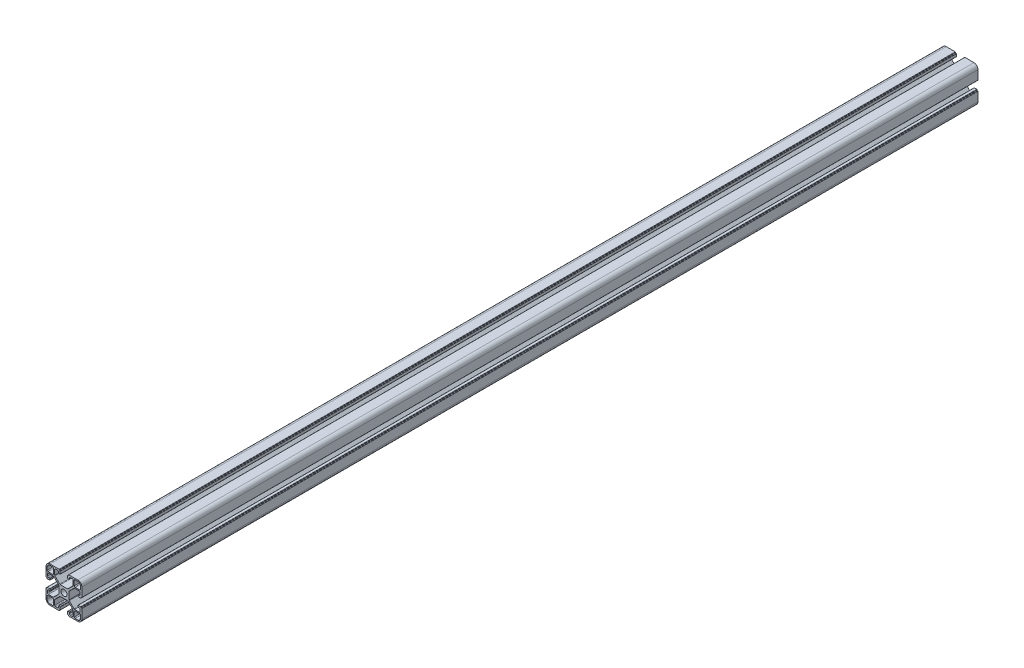
from build123d import *

# Parameters (mm, degrees)
SKETCH_1_R      = 3.4
EXTRUDE_1_DEPTH = 1000


with BuildPart() as part:
    # Эскиз1 → Бобышка-Вытянуть1 (new body)
    with BuildSketch(Plane.XY):
        with BuildLine():
            Line((-20, 10.25), (-20, 15.5))
            ThreePointArc((-20, 15.5), (-18.681980515, 18.681980515), (-15.5, 20))
            Line((-15.5, 20), (-10.25, 20))
            Line((-10.25, 20), (-5.4, 20))
            ThreePointArc((-5.4, 20), (-5.187867966, 19.912132034), (-5.1, 19.7))
            Line((-5.1, 19.7), (-5.1, 19.3))
            ThreePointArc((-5.1, 19.3), (-5.012132034, 19.087867966), (-4.8, 19))
            Line((-4.8, 19), (-4.4, 19))
            ThreePointArc((-4.4, 19), (-4.187867966, 18.912132034), (-4.1, 18.7))
            Line((-4.1, 18.7), (-4.1, 16))
            ThreePointArc((-4.1, 16), (-4.187867966, 15.787867966), (-4.4, 15.7))
            Line((-4.4, 15.7), (-5.8, 15.7))
            ThreePointArc((-5.8, 15.7), (-6.012132034, 15.787867966), (-6.1, 16))
            Line((-6.1, 16), (-6.1, 17.2))
            ThreePointArc((-6.1, 17.2), (-6.392893219, 17.907106781), (-7.1, 18.2))
            Line((-7.1, 18.2), (-9.25, 18.2))
            ThreePointArc((-9.25, 18.2), (-9.957106781, 17.907106781), (-10.25, 17.2))
            Line((-10.25, 17.2), (-10.25, 11.964213562))
            ThreePointArc((-10.25, 11.964213562), (-10.173879533, 11.58153013), (-9.957106781, 11.257106781))
            Line((-9.957106781, 11.257106781), (-4.692893219, 5.992893219))
            ThreePointArc((-4.692893219, 5.992893219), (-4.36846987, 5.776120467), (-3.985786438, 5.7))
            Line((-3.985786438, 5.7), (3.985786438, 5.7))
            ThreePointArc((3.985786438, 5.7), (4.36846987, 5.776120467), (4.692893219, 5.992893219))
            Line((4.692893219, 5.992893219), (9.957106781, 11.257106781))
            ThreePointArc((9.957106781, 11.257106781), (10.173879533, 11.58153013), (10.25, 11.964213562))
            Line((10.25, 11.964213562), (10.25, 17.2))
            ThreePointArc((10.25, 17.2), (9.957106781, 17.907106781), (9.25, 18.2))
            Line((9.25, 18.2), (7.1, 18.2))
            ThreePointArc((7.1, 18.2), (6.392893219, 17.907106781), (6.1, 17.2))
            Line((6.1, 17.2), (6.1, 16))
            ThreePointArc((6.1, 16), (6.012132034, 15.787867966), (5.8, 15.7))
            Line((5.8, 15.7), (4.4, 15.7))
            ThreePointArc((4.4, 15.7), (4.187867966, 15.787867966), (4.1, 16))
            Line((4.1, 16), (4.1, 18.7))
            ThreePointArc((4.1, 18.7), (4.187867966, 18.912132034), (4.4, 19))
            Line((4.4, 19), (4.8, 19))
            ThreePointArc((4.8, 19), (5.012132034, 19.087867966), (5.1, 19.3))
            Line((5.1, 19.3), (5.1, 19.7))
            ThreePointArc((5.1, 19.7), (5.187867966, 19.912132034), (5.4, 20))
            Line((5.4, 20), (10.25, 20))
            Line((10.25, 20), (15.5, 20))
            ThreePointArc((15.5, 20), (18.681980515, 18.681980515), (20, 15.5))
            Line((20, 15.5), (20, 10.25))
            Line((20, 10.25), (20, 5.4))
            ThreePointArc((20, 5.4), (19.912132034, 5.187867966), (19.7, 5.1))
            Line((19.7, 5.1), (19.3, 5.1))
            ThreePointArc((19.3, 5.1), (19.087867966, 5.012132034), (19, 4.8))
            Line((19, 4.8), (19, 4.4))
            ThreePointArc((19, 4.4), (18.912132034, 4.187867966), (18.7, 4.1))
            Line((18.7, 4.1), (16, 4.1))
            ThreePointArc((16, 4.1), (15.787867966, 4.187867966), (15.7, 4.4))
            Line((15.7, 4.4), (15.7, 5.8))
            ThreePointArc((15.7, 5.8), (15.787867966, 6.012132034), (16, 6.1))
            Line((16, 6.1), (17.2, 6.1))
            ThreePointArc((17.2, 6.1), (17.907106781, 6.392893219), (18.2, 7.1))
            Line((18.2, 7.1), (18.2, 9.25))
            ThreePointArc((18.2, 9.25), (17.907106781, 9.957106781), (17.2, 10.25))
            Line((17.2, 10.25), (11.964213562, 10.25))
            ThreePointArc((11.964213562, 10.25), (11.58153013, 10.173879533), (11.257106781, 9.957106781))
            Line((11.257106781, 9.957106781), (5.992893219, 4.692893219))
            ThreePointArc((5.992893219, 4.692893219), (5.776120467, 4.36846987), (5.7, 3.985786438))
            Line((5.7, 3.985786438), (5.7, -3.985786438))
            ThreePointArc((5.7, -3.985786438), (5.776120467, -4.36846987), (5.992893219, -4.692893219))
            Line((5.992893219, -4.692893219), (11.257106781, -9.957106781))
            ThreePointArc((11.257106781, -9.957106781), (11.58153013, -10.173879533), (11.964213562, -10.25))
            Line((11.964213562, -10.25), (17.2, -10.25))
            ThreePointArc((17.2, -10.25), (17.907106781, -9.957106781), (18.2, -9.25))
            Line((18.2, -9.25), (18.2, -7.1))
            ThreePointArc((18.2, -7.1), (17.907106781, -6.392893219), (17.2, -6.1))
            Line((17.2, -6.1), (16, -6.1))
            ThreePointArc((16, -6.1), (15.787867966, -6.012132034), (15.7, -5.8))
            Line((15.7, -5.8), (15.7, -4.4))
            ThreePointArc((15.7, -4.4), (15.787867966, -4.187867966), (16, -4.1))
            Line((16, -4.1), (18.7, -4.1))
            ThreePointArc((18.7, -4.1), (18.912132034, -4.187867966), (19, -4.4))
            Line((19, -4.4), (19, -4.8))
            ThreePointArc((19, -4.8), (19.087867966, -5.012132034), (19.3, -5.1))
            Line((19.3, -5.1), (19.7, -5.1))
            ThreePointArc((19.7, -5.1), (19.912132034, -5.187867966), (20, -5.4))
            Line((20, -5.4), (20, -10.25))
            Line((20, -10.25), (20, -15.5))
            ThreePointArc((20, -15.5), (18.681980515, -18.681980515), (15.5, -20))
            Line((15.5, -20), (10.25, -20))
            Line((10.25, -20), (5.4, -20))
            ThreePointArc((5.4, -20), (5.187867966, -19.912132034), (5.1, -19.7))
            Line((5.1, -19.7), (5.1, -19.3))
            ThreePointArc((5.1, -19.3), (5.012132034, -19.087867966), (4.8, -19))
            Line((4.8, -19), (4.4, -19))
            ThreePointArc((4.4, -19), (4.187867966, -18.912132034), (4.1, -18.7))
            Line((4.1, -18.7), (4.1, -16))
            ThreePointArc((4.1, -16), (4.187867966, -15.787867966), (4.4, -15.7))
            Line((4.4, -15.7), (5.8, -15.7))
            ThreePointArc((5.8, -15.7), (6.012132034, -15.787867966), (6.1, -16))
            Line((6.1, -16), (6.1, -17.2))
            ThreePointArc((6.1, -17.2), (6.392893219, -17.907106781), (7.1, -18.2))
            Line((7.1, -18.2), (9.25, -18.2))
            ThreePointArc((9.25, -18.2), (9.957106781, -17.907106781), (10.25, -17.2))
            Line((10.25, -17.2), (10.25, -11.964213562))
            ThreePointArc((10.25, -11.964213562), (10.173879533, -11.58153013), (9.957106781, -11.257106781))
            Line((9.957106781, -11.257106781), (4.692893219, -5.992893219))
            ThreePointArc((4.692893219, -5.992893219), (4.36846987, -5.776120467), (3.985786438, -5.7))
            Line((3.985786438, -5.7), (-3.985786438, -5.7))
            ThreePointArc((-3.985786438, -5.7), (-4.36846987, -5.776120467), (-4.692893219, -5.992893219))
            Line((-4.692893219, -5.992893219), (-9.957106781, -11.257106781))
            ThreePointArc((-9.957106781, -11.257106781), (-10.173879533, -11.58153013), (-10.25, -11.964213562))
            Line((-10.25, -11.964213562), (-10.25, -17.2))
            ThreePointArc((-10.25, -17.2), (-9.957106781, -17.907106781), (-9.25, -18.2))
            Line((-9.25, -18.2), (-7.1, -18.2))
            ThreePointArc((-7.1, -18.2), (-6.392893219, -17.907106781), (-6.1, -17.2))
            Line((-6.1, -17.2), (-6.1, -16))
            ThreePointArc((-6.1, -16), (-6.012132034, -15.787867966), (-5.8, -15.7))
            Line((-5.8, -15.7), (-4.4, -15.7))
            ThreePointArc((-4.4, -15.7), (-4.187867966, -15.787867966), (-4.1, -16))
            Line((-4.1, -16), (-4.1, -18.7))
            ThreePointArc((-4.1, -18.7), (-4.187867966, -18.912132034), (-4.4, -19))
            Line((-4.4, -19), (-4.8, -19))
            ThreePointArc((-4.8, -19), (-5.012132034, -19.087867966), (-5.1, -19.3))
            Line((-5.1, -19.3), (-5.1, -19.7))
            ThreePointArc((-5.1, -19.7), (-5.187867966, -19.912132034), (-5.4, -20))
            Line((-5.4, -20), (-10.25, -20))
            Line((-10.25, -20), (-15.5, -20))
            ThreePointArc((-15.5, -20), (-18.681980515, -18.681980515), (-20, -15.5))
            Line((-20, -15.5), (-20, -10.25))
            Line((-20, -10.25), (-20, -5.4))
            ThreePointArc((-20, -5.4), (-19.912132034, -5.187867966), (-19.7, -5.1))
            Line((-19.7, -5.1), (-19.3, -5.1))
            ThreePointArc((-19.3, -5.1), (-19.087867966, -5.012132034), (-19, -4.8))
            Line((-19, -4.8), (-19, -4.4))
            ThreePointArc((-19, -4.4), (-18.912132034, -4.187867966), (-18.7, -4.1))
            Line((-18.7, -4.1), (-16, -4.1))
            ThreePointArc((-16, -4.1), (-15.787867966, -4.187867966), (-15.7, -4.4))
            Line((-15.7, -4.4), (-15.7, -5.8))
            ThreePointArc((-15.7, -5.8), (-15.787867966, -6.012132034), (-16, -6.1))
            Line((-16, -6.1), (-17.2, -6.1))
            ThreePointArc((-17.2, -6.1), (-17.907106781, -6.392893219), (-18.2, -7.1))
            Line((-18.2, -7.1), (-18.2, -9.25))
            ThreePointArc((-18.2, -9.25), (-17.907106781, -9.957106781), (-17.2, -10.25))
            Line((-17.2, -10.25), (-11.964213562, -10.25))
            ThreePointArc((-11.964213562, -10.25), (-11.58153013, -10.173879533), (-11.257106781, -9.957106781))
            Line((-11.257106781, -9.957106781), (-5.992893219, -4.692893219))
            ThreePointArc((-5.992893219, -4.692893219), (-5.776120467, -4.36846987), (-5.7, -3.985786438))
            Line((-5.7, -3.985786438), (-5.7, 3.985786438))
            ThreePointArc((-5.7, 3.985786438), (-5.776120467, 4.36846987), (-5.992893219, 4.692893219))
            Line((-5.992893219, 4.692893219), (-11.257106781, 9.957106781))
            ThreePointArc((-11.257106781, 9.957106781), (-11.58153013, 10.173879533), (-11.964213562, 10.25))
            Line((-11.964213562, 10.25), (-17.2, 10.25))
            ThreePointArc((-17.2, 10.25), (-17.907106781, 9.957106781), (-18.2, 9.25))
            Line((-18.2, 9.25), (-18.2, 7.1))
            ThreePointArc((-18.2, 7.1), (-17.907106781, 6.392893219), (-17.2, 6.1))
            Line((-17.2, 6.1), (-16, 6.1))
            ThreePointArc((-16, 6.1), (-15.787867966, 6.012132034), (-15.7, 5.8))
            Line((-15.7, 5.8), (-15.7, 4.4))
            ThreePointArc((-15.7, 4.4), (-15.787867966, 4.187867966), (-16, 4.1))
            Line((-16, 4.1), (-18.7, 4.1))
            ThreePointArc((-18.7, 4.1), (-18.912132034, 4.187867966), (-19, 4.4))
            Line((-19, 4.4), (-19, 4.8))
            ThreePointArc((-19, 4.8), (-19.087867966, 5.012132034), (-19.3, 5.1))
            Line((-19.3, 5.1), (-19.7, 5.1))
            ThreePointArc((-19.7, 5.1), (-19.912132034, 5.187867966), (-20, 5.4))
            Line((-20, 5.4), (-20, 10.25))
        make_face()
        Circle(SKETCH_1_R, mode=Mode.SUBTRACT)
        with BuildLine():
            Line((-12.5, 11.5), (-17.7, 11.5))
            ThreePointArc((-17.7, 11.5), (-18.407106781, 11.792893219), (-18.7, 12.5))
            Line((-18.7, 12.5), (-18.7, 15.5))
            ThreePointArc((-18.7, 15.5), (-17.7627417, 17.7627417), (-15.5, 18.7))
            Line((-15.5, 18.7), (-12.5, 18.7))
            ThreePointArc((-12.5, 18.7), (-11.792893219, 18.407106781), (-11.5, 17.7))
            Line((-11.5, 17.7), (-11.5, 12.5))
            ThreePointArc((-11.5, 12.5), (-11.792893219, 11.792893219), (-12.5, 11.5))
        make_face(mode=Mode.SUBTRACT)
        with BuildLine():
            Line((11.5, 12.5), (11.5, 17.7))
            ThreePointArc((11.5, 17.7), (11.792893219, 18.407106781), (12.5, 18.7))
            Line((12.5, 18.7), (15.5, 18.7))
            ThreePointArc((15.5, 18.7), (17.7627417, 17.7627417), (18.7, 15.5))
            Line((18.7, 15.5), (18.7, 12.5))
            ThreePointArc((18.7, 12.5), (18.407106781, 11.792893219), (17.7, 11.5))
            Line((17.7, 11.5), (12.5, 11.5))
            ThreePointArc((12.5, 11.5), (11.792893219, 11.792893219), (11.5, 12.5))
        make_face(mode=Mode.SUBTRACT)
        with BuildLine():
            Line((12.5, -11.5), (17.7, -11.5))
            ThreePointArc((17.7, -11.5), (18.407106781, -11.792893219), (18.7, -12.5))
            Line((18.7, -12.5), (18.7, -15.5))
            ThreePointArc((18.7, -15.5), (17.7627417, -17.7627417), (15.5, -18.7))
            Line((15.5, -18.7), (12.5, -18.7))
            ThreePointArc((12.5, -18.7), (11.792893219, -18.407106781), (11.5, -17.7))
            Line((11.5, -17.7), (11.5, -12.5))
            ThreePointArc((11.5, -12.5), (11.792893219, -11.792893219), (12.5, -11.5))
        make_face(mode=Mode.SUBTRACT)
        with BuildLine():
            Line((-11.5, -12.5), (-11.5, -17.7))
            ThreePointArc((-11.5, -17.7), (-11.792893219, -18.407106781), (-12.5, -18.7))
            Line((-12.5, -18.7), (-15.5, -18.7))
            ThreePointArc((-15.5, -18.7), (-17.7627417, -17.7627417), (-18.7, -15.5))
            Line((-18.7, -15.5), (-18.7, -12.5))
            ThreePointArc((-18.7, -12.5), (-18.407106781, -11.792893219), (-17.7, -11.5))
            Line((-17.7, -11.5), (-12.5, -11.5))
            ThreePointArc((-12.5, -11.5), (-11.792893219, -11.792893219), (-11.5, -12.5))
        make_face(mode=Mode.SUBTRACT)
    extrude(amount=EXTRUDE_1_DEPTH)


solid = part.part
